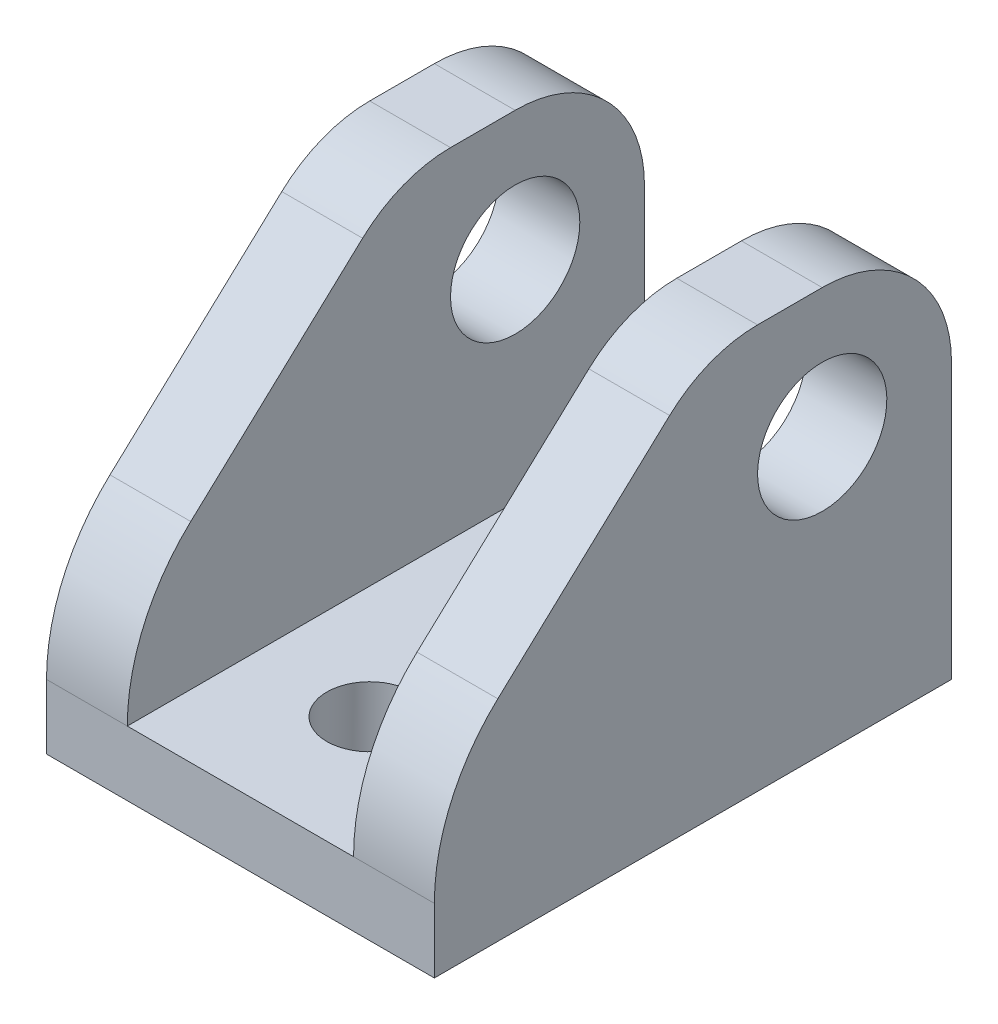
from build123d import *

# Parameters (mm, degrees)
BOSS_EXTRUDE1_DEPTH          = 50.8
CUT_EXTRUDE2_START           = -19.05
SKETCH2_3_R                  = 6.35
CUT_EXTRUDE2_DEPTH           = 3.175
SKETCH2_R                    = 6.35
CUT_EXTRUDE3_DEPTH           = 20.05
CUT_EXTRUDE3_DEPTH_BACK      = 20.05
F_5_16_CLEARANCE_HOLE1_D     = 8.4328
F_5_16_CLEARANCE_HOLE1_DEPTH = 19.05
F_5_16_CLEARANCE_HOLE1_TIP   = 2.533468714
CUT_EXTRUDE12_DEPTH          = 20.05
CUT_EXTRUDE12_DEPTH_BACK     = 20.05


with BuildPart() as part:
    # Sketch1 → Boss-Extrude1 (new body)
    with BuildSketch(Plane.XY):
        Polygon((-19.05, 0), (19.05, 0), (19.05, 50.8), (11.1125, 50.8), (11.1125, 6.35), (-11.1125, 6.35), (-11.1125, 50.8), (-19.05, 50.8), align=None)
    extrude(amount=BOSS_EXTRUDE1_DEPTH)

    # Sketch2_3 → Cut-Extrude2 (cut)
    with BuildSketch(Plane(origin=(0, 0, 0), x_dir=(0, 0, -1), z_dir=(1, 0, 0)).offset(CUT_EXTRUDE2_START)):
        with Locations((-12.7, 26.9875)):
            Circle(SKETCH2_3_R)
    cut_extrude2 = extrude(amount=CUT_EXTRUDE2_DEPTH, mode=Mode.SUBTRACT)

    # Mirror2: Cut-Extrude2 across plane
    add(cut_extrude2.mirror(Plane(origin=(0, 0, 0), x_dir=(0, 0, 1), z_dir=(1, 0, 0))), mode=Mode.SUBTRACT)

    # Sketch2 → Cut-Extrude3 (cut, two sides)
    with BuildSketch(Plane(origin=(0, 0, 0), x_dir=(0, 0, -1), z_dir=(1, 0, 0))) as cut_extrude3_sk:
        with Locations((-12.7, 26.9875)):
            Circle(SKETCH2_R)
    extrude(amount=CUT_EXTRUDE3_DEPTH, mode=Mode.SUBTRACT)
    extrude(cut_extrude3_sk.sketch, amount=-CUT_EXTRUDE3_DEPTH_BACK, mode=Mode.SUBTRACT)

    # 5_16 Clearance Hole1
    with Locations(Plane(origin=(0, 6.35, 0), x_dir=(1, 0, 0), z_dir=(0, 1, 0))):
        with Locations((0, -38.1), (0, -12.7)):
            Hole(F_5_16_CLEARANCE_HOLE1_D / 2, depth=F_5_16_CLEARANCE_HOLE1_DEPTH)
            with Locations((0, 0, -(F_5_16_CLEARANCE_HOLE1_DEPTH + F_5_16_CLEARANCE_HOLE1_TIP / 2))):  # 118° drill point
                Cone(0, F_5_16_CLEARANCE_HOLE1_D / 2, F_5_16_CLEARANCE_HOLE1_TIP, mode=Mode.SUBTRACT)

    # Sketch28 → Cut-Extrude12 (cut, two sides)
    with BuildSketch(Plane(origin=(0, 0, 0), x_dir=(0, 0, -1), z_dir=(1, 0, 0))) as cut_extrude12_sk:
        with BuildLine():
            Line((0, 50.8), (-50.8, 50.8))
            Line((-50.8, 50.8), (-50.8, 6.35))
            ThreePointArc((-50.8, 6.35), (-49.173704114, 14.144110837), (-44.566221155, 20.6375))
            Line((-44.566221155, 20.6375), (-27.687967891, 36.297468352))
            ThreePointArc((-27.687967891, 36.297468352), (-23.689687593, 38.809652893), (-19.05, 39.6875))
            Line((-19.05, 39.6875), (-12.7, 39.6875))
            ThreePointArc((-12.7, 39.6875), (-3.719743879, 35.967756121), (0, 26.9875))
            Line((0, 26.9875), (0, 50.8))
        make_face()
    extrude(amount=CUT_EXTRUDE12_DEPTH, mode=Mode.SUBTRACT)
    extrude(cut_extrude12_sk.sketch, amount=-CUT_EXTRUDE12_DEPTH_BACK, mode=Mode.SUBTRACT)


solid = part.part
